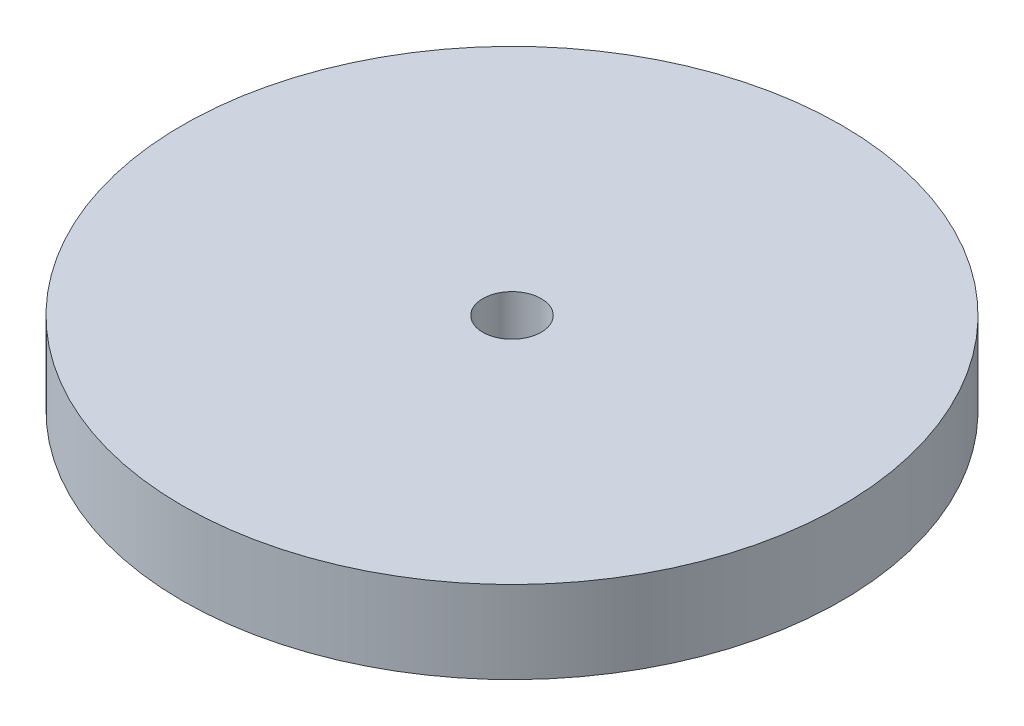
from build123d import *

# Parameters (mm, degrees)
SKETCH1_R           = 12.7
SKETCH1_R_2         = 1.125
BOSS_EXTRUDE1_DEPTH = 3.175


with BuildPart() as part:
    # Sketch1 → Boss-Extrude1 (new body)
    with BuildSketch(Plane(origin=(0, 0, 0), x_dir=(1, 0, 0), z_dir=(0, 1, 0))):
        Circle(SKETCH1_R)
        Circle(SKETCH1_R_2, mode=Mode.SUBTRACT)
    extrude(amount=-BOSS_EXTRUDE1_DEPTH)


solid = part.part
